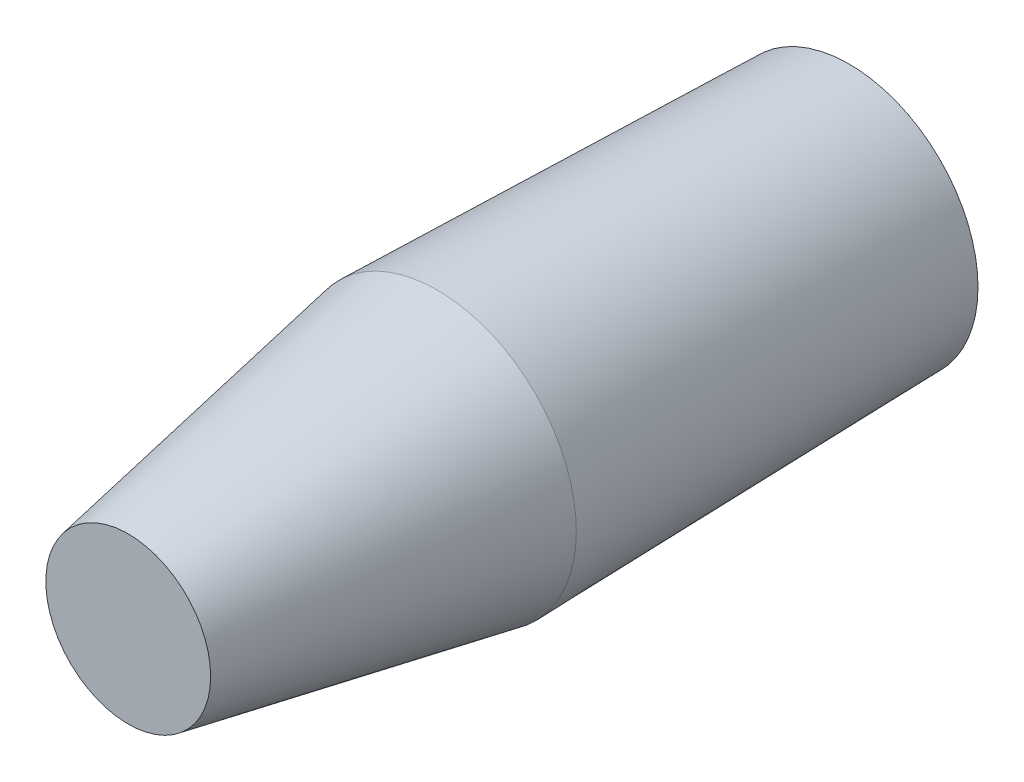
from build123d import *

# Parameters (mm, degrees)
SKETCH1_R = 25
SKETCH2_R = 27
SKETCH3_R = 16


with BuildPart() as part:
    # Sketch1 → Loft1 section 0
    with BuildSketch(Plane.XY):
        Circle(SKETCH1_R)
    # Sketch2 → Loft1 section 1
    with BuildSketch(Plane.XY.offset(80)):
        Circle(SKETCH2_R)
    loft()

    # Sketch3 → section 1 of loft2
    with BuildSketch(Plane.XY.offset(140), mode=Mode.PRIVATE) as loft2_s1:
        Circle(SKETCH3_R)
    # loft up to a face of the part (loft2)
    loft([Face(Wire([part.edges().sort_by_distance((-18.48277186, 19.68215294, 80))[0]])), loft2_s1.sketch])


solid = part.part
